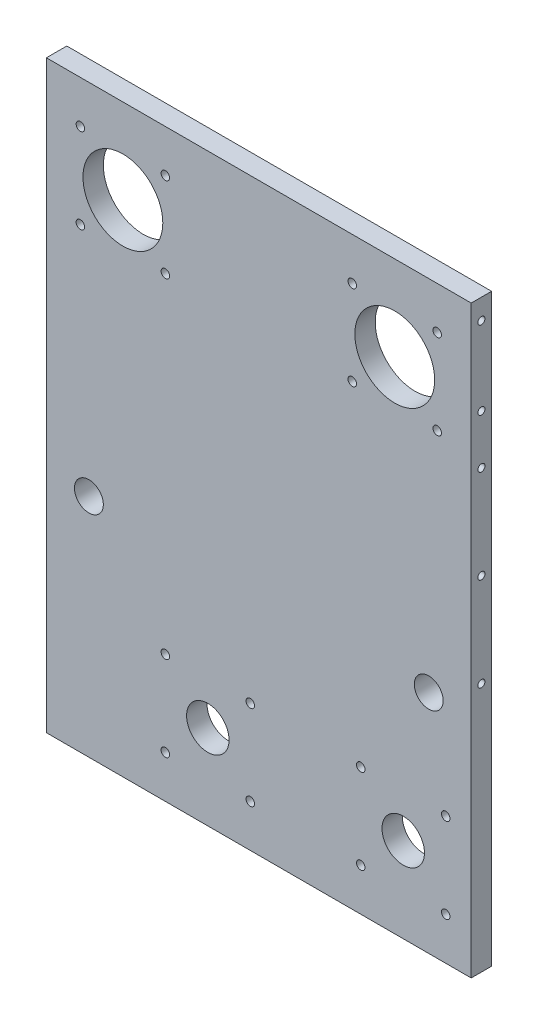
from build123d import *

# Parameters (mm, degrees)
SKETCH1_W                        = 250
SKETCH1_H                        = 344
SKETCH1_R                        = 23.5
SKETCH1_R_2                      = 8.5
SKETCH1_R_3                      = 12.5
BOSS_EXTRUDE1_DEPTH              = 12
TAP_DRILL_FOR_M5_TAP1_AT_2_COUNT = 2
TAP_DRILL_FOR_M5_TAP1_AT_2_PITCH = 46
TAP_DRILL_FOR_M6_TAP1_D          = 5
TAP_DRILL_FOR_M5_TAP2_D          = 4.2
TAP_DRILL_FOR_M5_TAP2_DEPTH      = 15
TAP_DRILL_FOR_M5_TAP2_TIP        = 1.2618073
TAP_DRILL_FOR_M5_TAP3_AT_2_COUNT = 2
TAP_DRILL_FOR_M5_TAP3_AT_2_PITCH = 55
TAP_DRILL_FOR_M5_TAP3_AT_3_COUNT = 2
TAP_DRILL_FOR_M5_TAP3_AT_3_PITCH = 110


with BuildPart() as part:
    # Sketch1 → Boss-Extrude1 (new body)
    with BuildSketch(Plane.XY):
        with Locations((0, 122)):
            Rectangle(SKETCH1_W, SKETCH1_H)
        with Locations((-80, 244)):
            Circle(SKETCH1_R, mode=Mode.SUBTRACT)
        with Locations((80, 244)):
            Circle(SKETCH1_R, mode=Mode.SUBTRACT)
        with Locations((-100, 83)):
            Circle(SKETCH1_R_2, mode=Mode.SUBTRACT)
        with Locations((100, 83)):
            Circle(SKETCH1_R_2, mode=Mode.SUBTRACT)
        with Locations((-30, 0)):
            Circle(SKETCH1_R_3, mode=Mode.SUBTRACT)
        with Locations((85, 0)):
            Circle(SKETCH1_R_3, mode=Mode.SUBTRACT)
    extrude(amount=BOSS_EXTRUDE1_DEPTH)

    # Sketch5 → Tap Drill for M5 Tap1 (revolve, cut)
    with BuildSketch(Plane(origin=(-125, 282, 6), x_dir=(0, 0, 1), z_dir=(0, 1, 0))):
        Polygon((0, 0), (0, 16.2618073), (2.1, 15), (2.1, 0), align=None)
    tap_drill_for_m5_tap1 = revolve(axis=Axis((-131.35, 282, 6), (1, 0, 0)), mode=Mode.SUBTRACT)

    # Tap Drill for M5 Tap1 at 2: Tap Drill for M5 Tap1 ×2
    with Locations(*[(0, -i * TAP_DRILL_FOR_M5_TAP1_AT_2_PITCH, 0) for i in range(1, TAP_DRILL_FOR_M5_TAP1_AT_2_COUNT)]):
        add(tap_drill_for_m5_tap1, mode=Mode.SUBTRACT)

    # Mirror1: Tap Drill for M5 Tap1 across plane
    add(tap_drill_for_m5_tap1.mirror(Plane(origin=(0, 0, 0), x_dir=(0, 0, 1), z_dir=(1, 0, 0))), mode=Mode.SUBTRACT)

    # Mirror1 copy 1 sketch → Mirror1 copy 1 (revolve, cut)
    with BuildSketch(Plane(origin=(125, 236, 6), x_dir=(0, 0, 1), z_dir=(0, 1, 0))):
        Polygon((0, 0), (0, -16.2618073), (2.1, -15), (2.1, 0), align=None)
    revolve(axis=Axis((131.35, 236, 6), (1, 0, 0)), mode=Mode.SUBTRACT)

    # Tap Drill for M6 Tap1 (through all)
    with Locations(Plane.XY.offset(12)):
        with Locations((-105, 269), (-55, 269), (-55, 219), (-105, 219), (55, 219), (105, 219), (105, 269), (55, 269), (-55, 25), (-5, 25), (-5, -25), (-55, -25), (60, 25), (110, 25), (110, -25), (60, -25)):
            Hole(TAP_DRILL_FOR_M6_TAP1_D / 2)

    # Tap Drill for M5 Tap2
    with Locations(Plane(origin=(0, -50, 0), x_dir=(-1, 0, 0), z_dir=(0, -1, 0))):
        with Locations((-113, -6), (-67, -6), (67, -6), (113, -6)):
            Hole(TAP_DRILL_FOR_M5_TAP2_D / 2, depth=TAP_DRILL_FOR_M5_TAP2_DEPTH)
            with Locations((0, 0, -(TAP_DRILL_FOR_M5_TAP2_DEPTH + TAP_DRILL_FOR_M5_TAP2_TIP / 2))):  # 118° drill point
                Cone(0, TAP_DRILL_FOR_M5_TAP2_D / 2, TAP_DRILL_FOR_M5_TAP2_TIP, mode=Mode.SUBTRACT)

    # Sketch19 → Tap Drill for M5 Tap3 (revolve, cut)
    with BuildSketch(Plane(origin=(125, 97, 6), x_dir=(0, 0, -1), z_dir=(0, 1, 0))):
        Polygon((0, 0), (0, 11.2618073), (2.1, 10), (2.1, 0), align=None)
    tap_drill_for_m5_tap3 = revolve(axis=Axis((131.35, 97, 6), (-1, 0, 0)), mode=Mode.SUBTRACT)

    # Tap Drill for M5 Tap3 at 2: Tap Drill for M5 Tap3 ×2
    with Locations(*[(0, i * TAP_DRILL_FOR_M5_TAP3_AT_2_PITCH, 0) for i in range(1, TAP_DRILL_FOR_M5_TAP3_AT_2_COUNT)]):
        add(tap_drill_for_m5_tap3, mode=Mode.SUBTRACT)

    # Tap Drill for M5 Tap3 at 3: Tap Drill for M5 Tap3 ×2
    with Locations(*[(0, i * TAP_DRILL_FOR_M5_TAP3_AT_3_PITCH, 0) for i in range(1, TAP_DRILL_FOR_M5_TAP3_AT_3_COUNT)]):
        add(tap_drill_for_m5_tap3, mode=Mode.SUBTRACT)

    # Mirror2: Tap Drill for M5 Tap3 across plane
    add(tap_drill_for_m5_tap3.mirror(Plane(origin=(0, 0, 0), x_dir=(0, 0, 1), z_dir=(1, 0, 0))), mode=Mode.SUBTRACT)

    # Mirror2 copy 1 sketch → Mirror2 copy 1 (revolve, cut)
    with BuildSketch(Plane(origin=(-125, 152, 6), x_dir=(0, 0, -1), z_dir=(0, 1, 0))):
        Polygon((0, 0), (0, -11.2618073), (2.1, -10), (2.1, 0), align=None)
    revolve(axis=Axis((-131.35, 152, 6), (-1, 0, 0)), mode=Mode.SUBTRACT)

    # Mirror2 copy 2 sketch → Mirror2 copy 2 (revolve, cut)
    with BuildSketch(Plane(origin=(-125, 207, 6), x_dir=(0, 0, -1), z_dir=(0, 1, 0))):
        Polygon((0, 0), (0, -11.2618073), (2.1, -10), (2.1, 0), align=None)
    revolve(axis=Axis((-131.35, 207, 6), (-1, 0, 0)), mode=Mode.SUBTRACT)


solid = part.part
